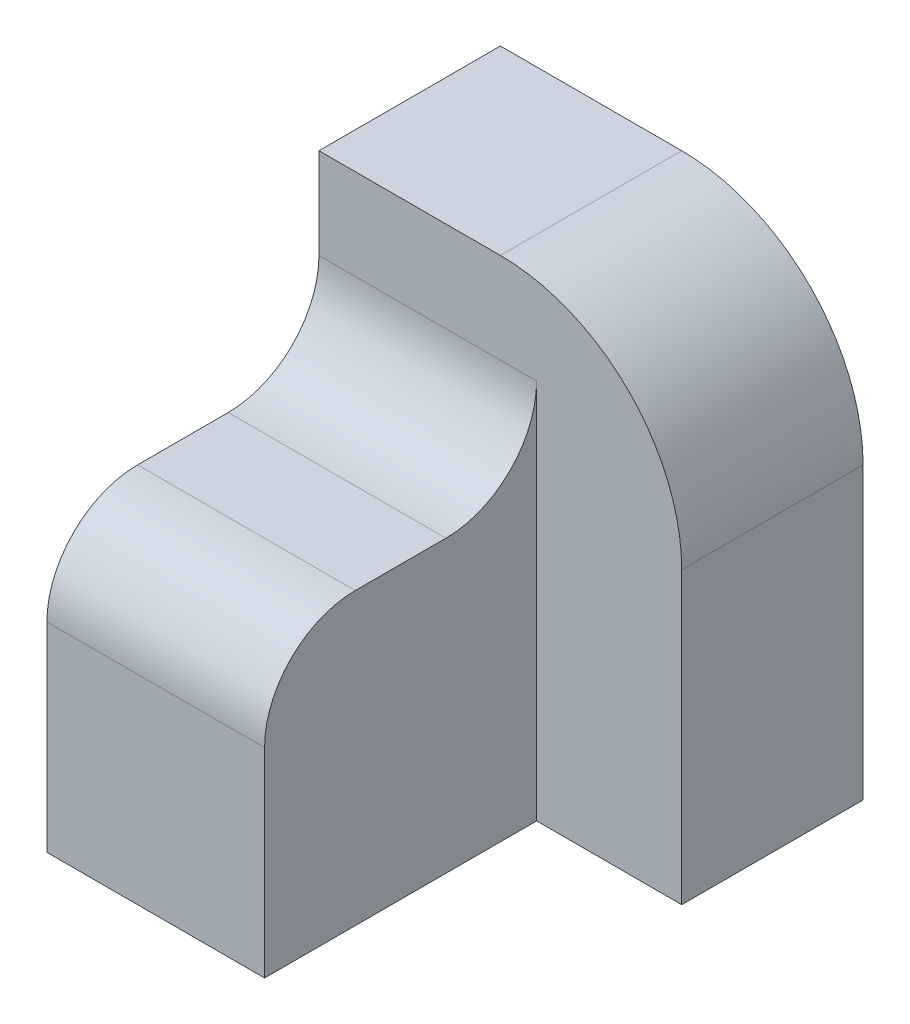
from build123d import *

# Parameters (mm, degrees)
SKETCH1_W               = 24
SKETCH1_H               = 30
BOSS_EXTRUDE1_DEPTH     = 60
CUT_EXTRUDE1_DEPTH      = 25
CUT_EXTRUDE1_DEPTH_BACK = 1
BOSS_EXTRUDE2_DEPTH     = 52
CUT_EXTRUDE3_DEPTH      = 31
CUT_EXTRUDE3_DEPTH_BACK = 20


with BuildPart() as part:
    # Sketch1 → Boss-Extrude1 (new body)
    with BuildSketch(Plane(origin=(0, 0, 0), x_dir=(1, 0, 0), z_dir=(0, 1, 0))):
        with Locations((12, 15)):
            Rectangle(SKETCH1_W, SKETCH1_H)
    extrude(amount=BOSS_EXTRUDE1_DEPTH)

    # Sketch2 → Cut-Extrude1 (cut, two sides)
    with BuildSketch(Plane(origin=(0, 0, 0), x_dir=(0, 0, -1), z_dir=(1, 0, 0))) as cut_extrude1_sk:
        with BuildLine():
            Line((0, 60), (0, 22))
            ThreePointArc((0, 22), (2.928932188, 29.071067812), (10, 32))
            Line((10, 32), (20, 32))
            ThreePointArc((20, 32), (27.071067812, 34.928932188), (30, 42))
            Line((30, 42), (30, 60))
            Line((30, 60), (0, 60))
        make_face()
    extrude(amount=CUT_EXTRUDE1_DEPTH, mode=Mode.SUBTRACT)
    extrude(cut_extrude1_sk.sketch, amount=-CUT_EXTRUDE1_DEPTH_BACK, mode=Mode.SUBTRACT)

    # Sketch1_5 → Boss-Extrude2 (add)
    with BuildSketch(Plane(origin=(0, 0, 0), x_dir=(1, 0, 0), z_dir=(0, 1, 0))):
        Polygon((0, 50), (0, 30), (24, 30), (40, 30), (40, 50), align=None)
    extrude(amount=BOSS_EXTRUDE2_DEPTH)

    # Sketch5 → Cut-Extrude3 (cut, two sides)
    with BuildSketch(Plane.XY.offset(-30)) as cut_extrude3_sk:
        with BuildLine():
            Line((-101.427106217, 52), (20, 52))
            ThreePointArc((20, 52), (34.142135624, 46.142135624), (40, 32))
            Line((40, 32), (40, -89.427106217))
            Line((40, -89.427106217), (211.723860452, 82.296754235))
            Line((211.723860452, 82.296754235), (70.296754235, 223.723860452))
            Line((70.296754235, 223.723860452), (-101.427106217, 52))
        make_face()
    extrude(amount=CUT_EXTRUDE3_DEPTH, mode=Mode.SUBTRACT)
    extrude(cut_extrude3_sk.sketch, amount=-CUT_EXTRUDE3_DEPTH_BACK, mode=Mode.SUBTRACT)


solid = part.part
